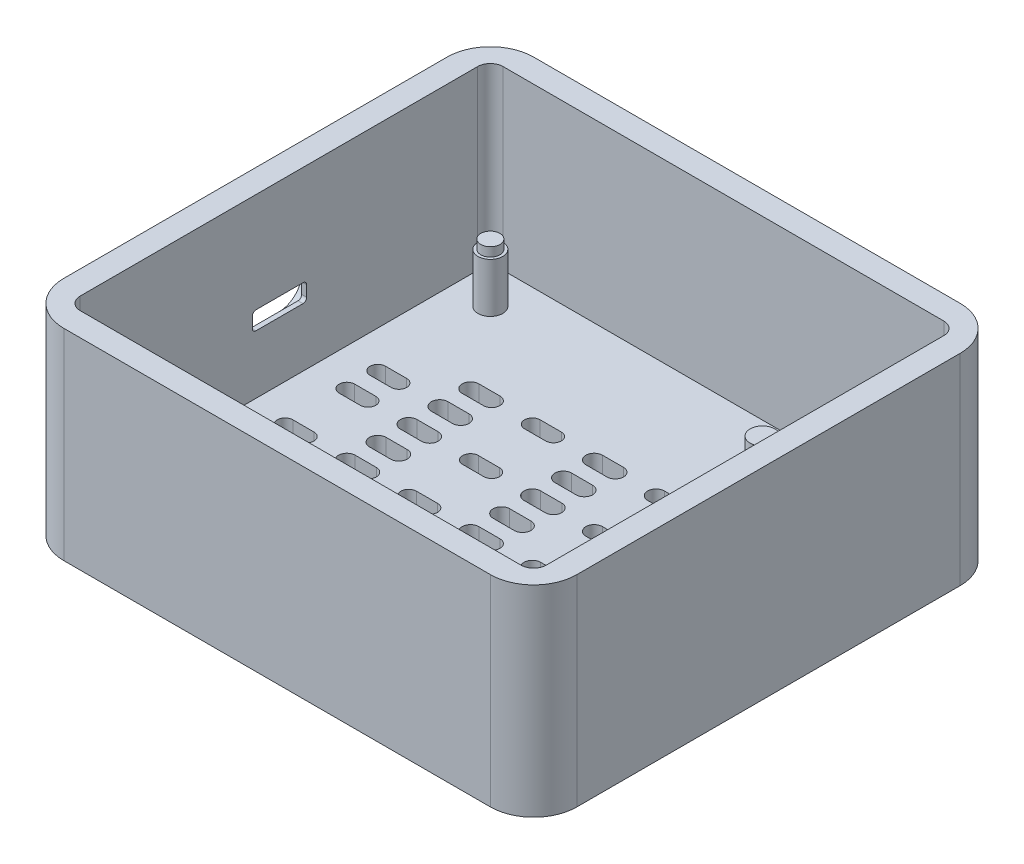
from build123d import *

# Parameters (mm, degrees)
EXTRUDE_1_DEPTH      = 4
CUT_EXTRUDE_1_DEPTH  = 65
SKETCH_7_R           = 2
EXTRUDE_4_DEPTH      = 8
SKETCH_8_R           = 1.55
EXTRUDE_5_DEPTH      = 1.461836357
SKETCH_9_R           = 1.55
EXTRUDE_6_DEPTH      = 1.451210787
SKETCH_10_R          = 2
EXTRUDE_7_DEPTH      = 8
EXTRUDE_8_DEPTH      = 28.55
CUT_EXTRUDE_2_DEPTH  = 9.55
CUT_EXTRUDE_3_DEPTH  = 3
CUT_EXTRUDE_4_DEPTH  = 24.55
SKETCH_16_W          = 7.6
SKETCH_16_H          = 0.085817923
CUT_EXTRUDE_5_DEPTH  = 32
CUT_EXTRUDE_7_DEPTH  = 32
EXTRUDE_9_DEPTH      = 4
EXTRUDE_10_DEPTH     = 4
CUT_EXTRUDE_9_DEPTH  = 2.7
CUT_EXTRUDE_10_DEPTH = 28.55
CUT_EXTRUDE_11_DEPTH = 0.3


with BuildPart() as part:
    # 草图1 → 凸台-拉伸1 (new body)
    with BuildSketch(Plane(origin=(0, 0, 0), x_dir=(1, 0, 0), z_dir=(0, 1, 0))):
        with BuildLine():
            Line((-34.5, 34), (34.5, 34))
            ThreePointArc((34.5, 34), (36.621320344, 33.121320344), (37.5, 31))
            Line((37.5, 31), (37.5, -31))
            ThreePointArc((37.5, -31), (36.621320344, -33.121320344), (34.5, -34))
            Line((34.5, -34), (-34.5, -34))
            ThreePointArc((-34.5, -34), (-36.621320344, -33.121320344), (-37.5, -31))
            Line((-37.5, -31), (-37.5, 31))
            ThreePointArc((-37.5, 31), (-36.621320344, 33.121320344), (-34.5, 34))
        make_face()
    extrude(amount=EXTRUDE_1_DEPTH)

    # 草图2 → 切除-拉伸1 (cut)
    with BuildSketch(Plane(origin=(0, 4, 0), x_dir=(1, 0, 0), z_dir=(0, 1, 0))):
        with BuildLine():
            Line((-1.709039215, 1.342816526), (1.709039215, 1.342816526))
            ThreePointArc((1.709039215, 1.342816526), (3.051855741, 0), (1.709039215, -1.342816526))
            Line((1.709039215, -1.342816526), (-1.709039215, -1.342816526))
            ThreePointArc((-1.709039215, -1.342816526), (-3.051855741, 0), (-1.709039215, 1.342816526))
        make_face()
        with BuildLine():
            Line((18.290960785, 1.342816526), (21.709039215, 1.342816526))
            ThreePointArc((21.709039215, 1.342816526), (23.051855741, 0), (21.709039215, -1.342816526))
            Line((21.709039215, -1.342816526), (18.290960785, -1.342816526))
            ThreePointArc((18.290960785, -1.342816526), (16.948144259, 0), (18.290960785, 1.342816526))
        make_face()
        with BuildLine():
            Line((-21.709039215, 1.342816526), (-18.290960785, 1.342816526))
            ThreePointArc((-18.290960785, 1.342816526), (-16.948144259, 0), (-18.290960785, -1.342816526))
            Line((-18.290960785, -1.342816526), (-21.709039215, -1.342816526))
            ThreePointArc((-21.709039215, -1.342816526), (-23.051855741, 0), (-21.709039215, 1.342816526))
        make_face()
        with BuildLine():
            Line((-1.709039215, -3.657183474), (1.709039215, -3.657183474))
            ThreePointArc((1.709039215, -3.657183474), (3.051855741, -5), (1.709039215, -6.342816526))
            Line((1.709039215, -6.342816526), (-1.709039215, -6.342816526))
            ThreePointArc((-1.709039215, -6.342816526), (-3.051855741, -5), (-1.709039215, -3.657183474))
        make_face()
        with BuildLine():
            Line((8.290960785, -3.657183474), (11.709039215, -3.657183474))
            ThreePointArc((11.709039215, -3.657183474), (13.051855741, -5), (11.709039215, -6.342816526))
            Line((11.709039215, -6.342816526), (8.290960785, -6.342816526))
            ThreePointArc((8.290960785, -6.342816526), (6.948144259, -5), (8.290960785, -3.657183474))
        make_face()
        with BuildLine():
            Line((18.290960785, -3.657183474), (21.709039215, -3.657183474))
            ThreePointArc((21.709039215, -3.657183474), (23.051855741, -5), (21.709039215, -6.342816526))
            Line((21.709039215, -6.342816526), (18.290960785, -6.342816526))
            ThreePointArc((18.290960785, -6.342816526), (16.948144259, -5), (18.290960785, -3.657183474))
        make_face()
        with BuildLine():
            Line((28.290960785, -3.657183474), (31.709039215, -3.657183474))
            ThreePointArc((31.709039215, -3.657183474), (33.051855741, -5), (31.709039215, -6.342816526))
            Line((31.709039215, -6.342816526), (28.290960785, -6.342816526))
            ThreePointArc((28.290960785, -6.342816526), (26.948144259, -5), (28.290960785, -3.657183474))
        make_face()
        with BuildLine():
            Line((-11.709039215, -3.738566294), (-8.290960785, -3.738566294))
            ThreePointArc((-8.290960785, -3.738566294), (-7.029527078, -5), (-8.290960785, -6.261433706))
            Line((-8.290960785, -6.261433706), (-11.709039215, -6.261433706))
            ThreePointArc((-11.709039215, -6.261433706), (-12.970472922, -5), (-11.709039215, -3.738566294))
        make_face()
        with BuildLine():
            Line((-21.709039215, -3.657183474), (-18.290960785, -3.657183474))
            ThreePointArc((-18.290960785, -3.657183474), (-16.948144259, -5), (-18.290960785, -6.342816526))
            Line((-18.290960785, -6.342816526), (-21.709039215, -6.342816526))
            ThreePointArc((-21.709039215, -6.342816526), (-23.051855741, -5), (-21.709039215, -3.657183474))
        make_face()
        with BuildLine():
            Line((-31.709039215, -3.738566294), (-28.290960785, -3.738566294))
            ThreePointArc((-28.290960785, -3.738566294), (-27.029527078, -5), (-28.290960785, -6.261433706))
            Line((-28.290960785, -6.261433706), (-31.709039215, -6.261433706))
            ThreePointArc((-31.709039215, -6.261433706), (-32.970472922, -5), (-31.709039215, -3.738566294))
        make_face()
        with BuildLine():
            Line((-1.709039215, -8.657183474), (1.709039215, -8.657183474))
            ThreePointArc((1.709039215, -8.657183474), (3.051855741, -10), (1.709039215, -11.342816526))
            Line((1.709039215, -11.342816526), (-1.709039215, -11.342816526))
            ThreePointArc((-1.709039215, -11.342816526), (-3.051855741, -10), (-1.709039215, -8.657183474))
        make_face()
        with BuildLine():
            Line((18.290960785, -8.657183474), (21.709039215, -8.657183474))
            ThreePointArc((21.709039215, -8.657183474), (23.051855741, -10), (21.709039215, -11.342816526))
            Line((21.709039215, -11.342816526), (18.290960785, -11.342816526))
            ThreePointArc((18.290960785, -11.342816526), (16.948144259, -10), (18.290960785, -8.657183474))
        make_face()
        with BuildLine():
            Line((28.290960785, -8.657183474), (31.709039215, -8.657183474))
            ThreePointArc((31.709039215, -8.657183474), (33.051855741, -10), (31.709039215, -11.342816526))
            Line((31.709039215, -11.342816526), (28.290960785, -11.342816526))
            ThreePointArc((28.290960785, -11.342816526), (26.948144259, -10), (28.290960785, -8.657183474))
        make_face()
        with BuildLine():
            Line((-21.709039215, -8.657183474), (-18.290960785, -8.657183474))
            ThreePointArc((-18.290960785, -8.657183474), (-16.948144259, -10), (-18.290960785, -11.342816526))
            Line((-18.290960785, -11.342816526), (-21.709039215, -11.342816526))
            ThreePointArc((-21.709039215, -11.342816526), (-23.051855741, -10), (-21.709039215, -8.657183474))
        make_face()
        with BuildLine():
            Line((-31.709039215, -8.738566294), (-28.290960785, -8.738566294))
            ThreePointArc((-28.290960785, -8.738566294), (-27.029527078, -10), (-28.290960785, -11.261433706))
            Line((-28.290960785, -11.261433706), (-31.709039215, -11.261433706))
            ThreePointArc((-31.709039215, -11.261433706), (-32.970472922, -10), (-31.709039215, -8.738566294))
        make_face()
        with BuildLine():
            Line((-1.709039215, -13.657183474), (1.709039215, -13.657183474))
            ThreePointArc((1.709039215, -13.657183474), (3.051855741, -15), (1.709039215, -16.342816526))
            Line((1.709039215, -16.342816526), (-1.709039215, -16.342816526))
            ThreePointArc((-1.709039215, -16.342816526), (-3.051855741, -15), (-1.709039215, -13.657183474))
        make_face()
        with BuildLine():
            Line((8.290960785, -13.657183474), (11.709039215, -13.657183474))
            ThreePointArc((11.709039215, -13.657183474), (13.051855741, -15), (11.709039215, -16.342816526))
            Line((11.709039215, -16.342816526), (8.290960785, -16.342816526))
            ThreePointArc((8.290960785, -16.342816526), (6.948144259, -15), (8.290960785, -13.657183474))
        make_face()
        with BuildLine():
            Line((18.290960785, -13.657183474), (21.709039215, -13.657183474))
            ThreePointArc((21.709039215, -13.657183474), (23.051855741, -15), (21.709039215, -16.342816526))
            Line((21.709039215, -16.342816526), (18.290960785, -16.342816526))
            ThreePointArc((18.290960785, -16.342816526), (16.948144259, -15), (18.290960785, -13.657183474))
        make_face()
        with BuildLine():
            Line((-11.709039215, -13.738566294), (-8.290960785, -13.738566294))
            ThreePointArc((-8.290960785, -13.738566294), (-7.029527078, -15), (-8.290960785, -16.261433706))
            Line((-8.290960785, -16.261433706), (-11.709039215, -16.261433706))
            ThreePointArc((-11.709039215, -16.261433706), (-12.970472922, -15), (-11.709039215, -13.738566294))
        make_face()
        with BuildLine():
            Line((-21.709039215, -13.657183474), (-18.290960785, -13.657183474))
            ThreePointArc((-18.290960785, -13.657183474), (-16.948144259, -15), (-18.290960785, -16.342816526))
            Line((-18.290960785, -16.342816526), (-21.709039215, -16.342816526))
            ThreePointArc((-21.709039215, -16.342816526), (-23.051855741, -15), (-21.709039215, -13.657183474))
        make_face()
        with BuildLine():
            Line((-1.709039215, 6.342816526), (1.709039215, 6.342816526))
            ThreePointArc((1.709039215, 6.342816526), (3.051855741, 5), (1.709039215, 3.657183474))
            Line((1.709039215, 3.657183474), (-1.709039215, 3.657183474))
            ThreePointArc((-1.709039215, 3.657183474), (-3.051855741, 5), (-1.709039215, 6.342816526))
        make_face()
        with BuildLine():
            Line((8.290960785, 6.342816526), (11.709039215, 6.342816526))
            ThreePointArc((11.709039215, 6.342816526), (13.051855741, 5), (11.709039215, 3.657183474))
            Line((11.709039215, 3.657183474), (8.290960785, 3.657183474))
            ThreePointArc((8.290960785, 3.657183474), (6.948144259, 5), (8.290960785, 6.342816526))
        make_face()
        with BuildLine():
            Line((18.290960785, 6.342816526), (21.709039215, 6.342816526))
            ThreePointArc((21.709039215, 6.342816526), (23.051855741, 5), (21.709039215, 3.657183474))
            Line((21.709039215, 3.657183474), (18.290960785, 3.657183474))
            ThreePointArc((18.290960785, 3.657183474), (16.948144259, 5), (18.290960785, 6.342816526))
        make_face()
        with BuildLine():
            Line((28.290960785, 6.342816526), (31.709039215, 6.342816526))
            ThreePointArc((31.709039215, 6.342816526), (33.051855741, 5), (31.709039215, 3.657183474))
            Line((31.709039215, 3.657183474), (28.290960785, 3.657183474))
            ThreePointArc((28.290960785, 3.657183474), (26.948144259, 5), (28.290960785, 6.342816526))
        make_face()
        with BuildLine():
            Line((-11.709039215, 6.261433706), (-8.290960785, 6.261433706))
            ThreePointArc((-8.290960785, 6.261433706), (-7.029527078, 5), (-8.290960785, 3.738566294))
            Line((-8.290960785, 3.738566294), (-11.709039215, 3.738566294))
            ThreePointArc((-11.709039215, 3.738566294), (-12.970472922, 5), (-11.709039215, 6.261433706))
        make_face()
        with BuildLine():
            Line((-21.709039215, 6.342816526), (-18.290960785, 6.342816526))
            ThreePointArc((-18.290960785, 6.342816526), (-16.948144259, 5), (-18.290960785, 3.657183474))
            Line((-18.290960785, 3.657183474), (-21.709039215, 3.657183474))
            ThreePointArc((-21.709039215, 3.657183474), (-23.051855741, 5), (-21.709039215, 6.342816526))
        make_face()
        with BuildLine():
            Line((-31.709039215, 6.261433706), (-28.290960785, 6.261433706))
            ThreePointArc((-28.290960785, 6.261433706), (-27.029527078, 5), (-28.290960785, 3.738566294))
            Line((-28.290960785, 3.738566294), (-31.709039215, 3.738566294))
            ThreePointArc((-31.709039215, 3.738566294), (-32.970472922, 5), (-31.709039215, 6.261433706))
        make_face()
        with BuildLine():
            Line((-1.709039215, 11.342816526), (1.709039215, 11.342816526))
            ThreePointArc((1.709039215, 11.342816526), (3.051855741, 10), (1.709039215, 8.657183474))
            Line((1.709039215, 8.657183474), (-1.709039215, 8.657183474))
            ThreePointArc((-1.709039215, 8.657183474), (-3.051855741, 10), (-1.709039215, 11.342816526))
        make_face()
        with BuildLine():
            Line((18.290960785, 11.342816526), (21.709039215, 11.342816526))
            ThreePointArc((21.709039215, 11.342816526), (23.051855741, 10), (21.709039215, 8.657183474))
            Line((21.709039215, 8.657183474), (18.290960785, 8.657183474))
            ThreePointArc((18.290960785, 8.657183474), (16.948144259, 10), (18.290960785, 11.342816526))
        make_face()
        with BuildLine():
            Line((28.290960785, 11.342816526), (31.709039215, 11.342816526))
            ThreePointArc((31.709039215, 11.342816526), (33.051855741, 10), (31.709039215, 8.657183474))
            Line((31.709039215, 8.657183474), (28.290960785, 8.657183474))
            ThreePointArc((28.290960785, 8.657183474), (26.948144259, 10), (28.290960785, 11.342816526))
        make_face()
        with BuildLine():
            Line((-21.709039215, 11.342816526), (-18.290960785, 11.342816526))
            ThreePointArc((-18.290960785, 11.342816526), (-16.948144259, 10), (-18.290960785, 8.657183474))
            Line((-18.290960785, 8.657183474), (-21.709039215, 8.657183474))
            ThreePointArc((-21.709039215, 8.657183474), (-23.051855741, 10), (-21.709039215, 11.342816526))
        make_face()
        with BuildLine():
            Line((-31.709039215, 11.261433706), (-28.290960785, 11.261433706))
            ThreePointArc((-28.290960785, 11.261433706), (-27.029527078, 10), (-28.290960785, 8.738566294))
            Line((-28.290960785, 8.738566294), (-31.709039215, 8.738566294))
            ThreePointArc((-31.709039215, 8.738566294), (-32.970472922, 10), (-31.709039215, 11.261433706))
        make_face()
        with BuildLine():
            Line((-1.709039215, 16.342816526), (1.709039215, 16.342816526))
            ThreePointArc((1.709039215, 16.342816526), (3.051855741, 15), (1.709039215, 13.657183474))
            Line((1.709039215, 13.657183474), (-1.709039215, 13.657183474))
            ThreePointArc((-1.709039215, 13.657183474), (-3.051855741, 15), (-1.709039215, 16.342816526))
        make_face()
        with BuildLine():
            Line((8.290960785, 16.342816526), (11.709039215, 16.342816526))
            ThreePointArc((11.709039215, 16.342816526), (13.051855741, 15), (11.709039215, 13.657183474))
            Line((11.709039215, 13.657183474), (8.290960785, 13.657183474))
            ThreePointArc((8.290960785, 13.657183474), (6.948144259, 15), (8.290960785, 16.342816526))
        make_face()
        with BuildLine():
            Line((18.290960785, 16.342816526), (21.709039215, 16.342816526))
            ThreePointArc((21.709039215, 16.342816526), (23.051855741, 15), (21.709039215, 13.657183474))
            Line((21.709039215, 13.657183474), (18.290960785, 13.657183474))
            ThreePointArc((18.290960785, 13.657183474), (16.948144259, 15), (18.290960785, 16.342816526))
        make_face()
        with BuildLine():
            Line((-11.709039215, 16.261433706), (-8.290960785, 16.261433706))
            ThreePointArc((-8.290960785, 16.261433706), (-7.029527078, 15), (-8.290960785, 13.738566294))
            Line((-8.290960785, 13.738566294), (-11.709039215, 13.738566294))
            ThreePointArc((-11.709039215, 13.738566294), (-12.970472922, 15), (-11.709039215, 16.261433706))
        make_face()
        with BuildLine():
            Line((-21.709039215, 16.342816526), (-18.290960785, 16.342816526))
            ThreePointArc((-18.290960785, 16.342816526), (-16.948144259, 15), (-18.290960785, 13.657183474))
            Line((-18.290960785, 13.657183474), (-21.709039215, 13.657183474))
            ThreePointArc((-21.709039215, 13.657183474), (-23.051855741, 15), (-21.709039215, 16.342816526))
        make_face()
    extrude(amount=-CUT_EXTRUDE_1_DEPTH, mode=Mode.SUBTRACT)

    # 草图7 → 凸台-拉伸4 (add)
    with BuildSketch(Plane(origin=(0, 4, 0), x_dir=(1, 0, 0), z_dir=(0, 1, 0))):
        with Locations((-31.621320344, 28.121320344)):
            Circle(SKETCH_7_R)
        with Locations((-31.621320344, -28.121320344)):
            Circle(SKETCH_7_R)
    extrude(amount=EXTRUDE_4_DEPTH)

    # 草图8 → 凸台-拉伸5 (add)
    with BuildSketch(Plane(origin=(0, 12, 0), x_dir=(1, 0, 0), z_dir=(0, 1, 0))):
        with Locations((-31.621320344, -28.121320344)):
            Circle(SKETCH_8_R)
    extrude(amount=EXTRUDE_5_DEPTH)

    # 草图9 → 凸台-拉伸6 (add)
    with BuildSketch(Plane(origin=(0, 12, 0), x_dir=(1, 0, 0), z_dir=(0, 1, 0))):
        with Locations((-31.621320344, 28.121320344)):
            Circle(SKETCH_9_R)
    extrude(amount=EXTRUDE_6_DEPTH)

    # 草图10 → 凸台-拉伸7 (add)
    with BuildSketch(Plane(origin=(0, 4, 0), x_dir=(1, 0, 0), z_dir=(0, 1, 0))):
        with Locations((16.546, -27.048136821)):
            Circle(SKETCH_10_R)
        with Locations((16.546, 23.975895567)):
            Circle(SKETCH_10_R)
    extrude(amount=EXTRUDE_7_DEPTH)

    # 草图11 → 凸台-拉伸8 (add)
    with BuildSketch(Plane.XZ):
        with BuildLine():
            Line((-34.5, -38), (34.5, -38))
            ThreePointArc((34.5, -38), (39.449747468, -35.949747468), (41.5, -31))
            Line((41.5, -31), (41.5, 31))
            ThreePointArc((41.5, 31), (39.449747468, 35.949747468), (34.5, 38))
            Line((34.5, 38), (-34.5, 38))
            ThreePointArc((-34.5, 38), (-39.449747468, 35.949747468), (-41.5, 31))
            Line((-41.5, 31), (-41.5, -31))
            ThreePointArc((-41.5, -31), (-39.449747468, -35.949747468), (-34.5, -38))
        make_face()
        with BuildLine():
            Line((-34.5, -34), (34.5, -34))
            ThreePointArc((34.5, -34), (36.621320344, -33.121320344), (37.5, -31))
            Line((37.5, -31), (37.5, 31))
            ThreePointArc((37.5, 31), (36.621320344, 33.121320344), (34.5, 34))
            Line((34.5, 34), (-34.5, 34))
            ThreePointArc((-34.5, 34), (-36.621320344, 33.121320344), (-37.5, 31))
            Line((-37.5, 31), (-37.5, -31))
            ThreePointArc((-37.5, -31), (-36.621320344, -33.121320344), (-34.5, -34))
        make_face(mode=Mode.SUBTRACT)
    extrude(amount=-EXTRUDE_8_DEPTH)

    # 草图12 → 切除-拉伸2 (cut)
    with BuildSketch(Plane.ZY.offset(41.5)):
        with BuildLine():
            Line((-3.8715, 9.55), (3.7285, 9.55))
            ThreePointArc((3.7285, 9.55), (4.152764069, 9.725735931), (4.3285, 10.15))
            Line((4.3285, 10.15), (4.3285, 11.8))
            ThreePointArc((4.3285, 11.8), (4.152764069, 12.224264069), (3.7285, 12.4))
            Line((3.7285, 12.4), (-3.8715, 12.4))
            ThreePointArc((-3.8715, 12.4), (-4.295764069, 12.224264069), (-4.4715, 11.8))
            Line((-4.4715, 11.8), (-4.4715, 10.15))
            ThreePointArc((-4.4715, 10.15), (-4.295764069, 9.725735931), (-3.8715, 9.55))
        make_face()
    extrude(amount=-CUT_EXTRUDE_2_DEPTH, mode=Mode.SUBTRACT)

    # 草图13 → 切除-拉伸3 (cut)
    with BuildSketch(Plane.ZY.offset(41.5)):
        with BuildLine():
            Line((3.7285, 14.4), (-3.8715, 14.4))
            ThreePointArc((-3.8715, 14.4), (-5.709977631, 13.638477631), (-6.4715, 11.8))
            Line((-6.4715, 11.8), (-6.4715, 10.15))
            ThreePointArc((-6.4715, 10.15), (-5.709977631, 8.311522369), (-3.8715, 7.55))
            Line((-3.8715, 7.55), (3.7285, 7.55))
            ThreePointArc((3.7285, 7.55), (5.566977631, 8.311522369), (6.3285, 10.15))
            Line((6.3285, 10.15), (6.3285, 11.8))
            ThreePointArc((6.3285, 11.8), (5.566977631, 13.638477631), (3.7285, 14.4))
        make_face()
    extrude(amount=-CUT_EXTRUDE_3_DEPTH, mode=Mode.SUBTRACT)

    # 草图15 → 切除-拉伸4 (cut)
    with BuildSketch(Plane(origin=(0, 28.55, 0), x_dir=(1, 0, 0), z_dir=(0, 1, 0))):
        with BuildLine():
            ThreePointArc((-35.65, -34), (-36.958147545, -33.458147545), (-37.5, -32.15))
            Line((-37.5, -32.15), (-37.5, -31))
            ThreePointArc((-37.5, -31), (-36.621320344, -33.121320344), (-34.5, -34))
            Line((-34.5, -34), (-35.65, -34))
        make_face()
        with BuildLine():
            Line((34.5, -34), (35.65, -34))
            ThreePointArc((35.65, -34), (36.958147545, -33.458147545), (37.5, -32.15))
            Line((37.5, -32.15), (37.5, -31))
            ThreePointArc((37.5, -31), (36.621320344, -33.121320344), (34.5, -34))
        make_face()
        with BuildLine():
            Line((-37.5, 32.15), (-37.5, 31))
            ThreePointArc((-37.5, 31), (-36.621320344, 33.121320344), (-34.5, 34))
            Line((-34.5, 34), (-35.65, 34))
            ThreePointArc((-35.65, 34), (-36.958147545, 33.458147545), (-37.5, 32.15))
        make_face()
        with BuildLine():
            ThreePointArc((35.65, 34), (36.958147545, 33.458147545), (37.5, 32.15))
            Line((37.5, 32.15), (37.5, 31))
            ThreePointArc((37.5, 31), (36.621320344, 33.121320344), (34.5, 34))
            Line((34.5, 34), (35.65, 34))
        make_face()
    extrude(amount=-CUT_EXTRUDE_4_DEPTH, mode=Mode.SUBTRACT)

    # 草图16 → 切除-拉伸5 (cut)
    with BuildSketch(Plane.ZY.offset(38.5)):
        with Locations((-0.0715, 9.507091039)):
            Rectangle(SKETCH_16_W, SKETCH_16_H)
        with BuildLine():
            ThreePointArc((-3.8715, 9.464182077), (-4.295764069, 9.639918008), (-4.4715, 10.064182077))
            Line((-4.4715, 10.064182077), (-4.4715, 10.15))
            ThreePointArc((-4.4715, 10.15), (-4.295764069, 9.725735931), (-3.8715, 9.55))
            Line((-3.8715, 9.55), (-3.8715, 9.464182077))
        make_face()
        with BuildLine():
            Line((3.7285, 9.55), (3.7285, 9.464182077))
            ThreePointArc((3.7285, 9.464182077), (4.152764069, 9.639918008), (4.3285, 10.064182077))
            Line((4.3285, 10.064182077), (4.3285, 10.15))
            ThreePointArc((4.3285, 10.15), (4.152764069, 9.725735931), (3.7285, 9.55))
        make_face()
    extrude(amount=-CUT_EXTRUDE_5_DEPTH, mode=Mode.SUBTRACT)

    # 草图19 → 切除-拉伸7 (cut)
    with BuildSketch(Plane.ZY.offset(41.5)):
        with BuildLine():
            Line((-4.483592089, 15.8), (-4.483592089, 14.064182077))
            ThreePointArc((-4.483592089, 14.064182077), (-4.307856158, 13.639918008), (-3.883592089, 13.464182077))
            Line((-3.883592089, 13.464182077), (3.716407911, 13.464182077))
            ThreePointArc((3.716407911, 13.464182077), (4.14067198, 13.639918008), (4.316407911, 14.064182077))
            Line((4.316407911, 14.064182077), (4.316407911, 15.8))
            ThreePointArc((4.316407911, 15.8), (4.14067198, 16.224264069), (3.716407911, 16.4))
            Line((3.716407911, 16.4), (-3.883592089, 16.4))
            ThreePointArc((-3.883592089, 16.4), (-4.307856158, 16.224264069), (-4.483592089, 15.8))
        make_face()
    extrude(amount=-CUT_EXTRUDE_7_DEPTH, mode=Mode.SUBTRACT)

    # 草图21 → 凸台-拉伸9 (add)
    with BuildSketch(Plane(origin=(0, 28.55, 0), x_dir=(1, 0, 0), z_dir=(0, 1, 0))):
        with BuildLine():
            Line((-41.5, 31), (-41.5, -31))
            ThreePointArc((-41.5, -31), (-39.449747468, -35.949747468), (-34.5, -38))
            Line((-34.5, -38), (34.5, -38))
            ThreePointArc((34.5, -38), (39.449747468, -35.949747468), (41.5, -31))
            Line((41.5, -31), (41.5, 31))
            ThreePointArc((41.5, 31), (39.449747468, 35.949747468), (34.5, 38))
            Line((34.5, 38), (-34.5, 38))
            ThreePointArc((-34.5, 38), (-39.449747468, 35.949747468), (-41.5, 31))
        make_face()
        with BuildLine():
            Line((-35.65, -34), (35.65, -34))
            ThreePointArc((35.65, -34), (36.958147545, -33.458147545), (37.5, -32.15))
            Line((37.5, -32.15), (37.5, 32.15))
            ThreePointArc((37.5, 32.15), (36.958147545, 33.458147545), (35.65, 34))
            Line((35.65, 34), (-35.65, 34))
            ThreePointArc((-35.65, 34), (-36.958147545, 33.458147545), (-37.5, 32.15))
            Line((-37.5, 32.15), (-37.5, -32.15))
            ThreePointArc((-37.5, -32.15), (-36.958147545, -33.458147545), (-35.65, -34))
        make_face(mode=Mode.SUBTRACT)
    extrude(amount=EXTRUDE_9_DEPTH)

    # 草图22 → 凸台-拉伸10 (add)
    with BuildSketch(Plane.ZY.offset(41.5)):
        with BuildLine():
            Line((4.316407911, 14.332659529), (4.316407911, 14.064182077))
            ThreePointArc((4.316407911, 14.064182077), (4.14067198, 13.639918008), (3.716407911, 13.464182077))
            Line((3.716407911, 13.464182077), (-3.883592089, 13.464182077))
            ThreePointArc((-3.883592089, 13.464182077), (-4.307856158, 13.639918008), (-4.483592089, 14.064182077))
            Line((-4.483592089, 14.064182077), (-4.483592089, 14.326923678))
            ThreePointArc((-4.483592089, 14.326923678), (-5.914957784, 13.407569683), (-6.4715, 11.8))
            Line((-6.4715, 11.8), (-6.4715, 10.15))
            ThreePointArc((-6.4715, 10.15), (-5.709977631, 8.311522369), (-3.8715, 7.55))
            Line((-3.8715, 7.55), (3.7285, 7.55))
            ThreePointArc((3.7285, 7.55), (5.566977631, 8.311522369), (6.3285, 10.15))
            Line((6.3285, 10.15), (6.3285, 11.8))
            ThreePointArc((6.3285, 11.8), (5.764250546, 13.417318681), (4.316407911, 14.332659529))
        make_face()
    extrude(amount=-EXTRUDE_10_DEPTH)

    # 草图23 → 切除-拉伸9 (cut)
    with BuildSketch(Plane.ZY.offset(41.5)):
        with BuildLine():
            Line((7.316407911, 15.8), (7.316407911, 14.064182077))
            ThreePointArc((7.316407911, 14.064182077), (6.261992323, 11.518597665), (3.716407911, 10.464182077))
            Line((3.716407911, 10.464182077), (-3.883592089, 10.464182077))
            ThreePointArc((-3.883592089, 10.464182077), (-6.429176501, 11.518597665), (-7.483592089, 14.064182077))
            Line((-7.483592089, 14.064182077), (-7.483592089, 15.8))
            ThreePointArc((-7.483592089, 15.8), (-6.429176501, 18.345584412), (-3.883592089, 19.4))
            Line((-3.883592089, 19.4), (3.716407911, 19.4))
            ThreePointArc((3.716407911, 19.4), (6.261992323, 18.345584412), (7.316407911, 15.8))
        make_face()
        with BuildLine():
            Line((4.316407911, 15.8), (4.316407911, 14.064182077))
            ThreePointArc((4.316407911, 14.064182077), (4.14067198, 13.639918008), (3.716407911, 13.464182077))
            Line((3.716407911, 13.464182077), (-3.883592089, 13.464182077))
            ThreePointArc((-3.883592089, 13.464182077), (-4.307856158, 13.639918008), (-4.483592089, 14.064182077))
            Line((-4.483592089, 14.064182077), (-4.483592089, 15.8))
            ThreePointArc((-4.483592089, 15.8), (-4.307856158, 16.224264069), (-3.883592089, 16.4))
            Line((-3.883592089, 16.4), (3.716407911, 16.4))
            ThreePointArc((3.716407911, 16.4), (4.14067198, 16.224264069), (4.316407911, 15.8))
        make_face(mode=Mode.SUBTRACT)
    extrude(amount=-CUT_EXTRUDE_9_DEPTH, mode=Mode.SUBTRACT)

    # 草图25 → 切除-拉伸10 (cut)
    with BuildSketch(Plane(origin=(0, 32.55, 0), x_dir=(1, 0, 0), z_dir=(0, 1, 0))):
        with BuildLine():
            Line((-37.7, 32.15), (-37.7, -32.15))
            ThreePointArc((-37.7, -32.15), (-37.099568901, -33.599568901), (-35.65, -34.2))
            Line((-35.65, -34.2), (35.65, -34.2))
            ThreePointArc((35.65, -34.2), (37.099568901, -33.599568901), (37.7, -32.15))
            Line((37.7, -32.15), (37.7, 32.15))
            ThreePointArc((37.7, 32.15), (37.099568901, 33.599568901), (35.65, 34.2))
            Line((35.65, 34.2), (-35.65, 34.2))
            ThreePointArc((-35.65, 34.2), (-37.099568901, 33.599568901), (-37.7, 32.15))
        make_face()
        with BuildLine():
            ThreePointArc((-35.65, -34), (-36.958147545, -33.458147545), (-37.5, -32.15))
            Line((-37.5, -32.15), (-37.5, 32.15))
            ThreePointArc((-37.5, 32.15), (-36.958147545, 33.458147545), (-35.65, 34))
            Line((-35.65, 34), (35.65, 34))
            ThreePointArc((35.65, 34), (36.958147545, 33.458147545), (37.5, 32.15))
            Line((37.5, 32.15), (37.5, -32.15))
            ThreePointArc((37.5, -32.15), (36.958147545, -33.458147545), (35.65, -34))
            Line((35.65, -34), (-35.65, -34))
        make_face(mode=Mode.SUBTRACT)
    extrude(amount=-CUT_EXTRUDE_10_DEPTH, mode=Mode.SUBTRACT)

    # 草图26 → 切除-拉伸11 (cut)
    with BuildSketch(Plane.ZY.offset(38.8)):
        with BuildLine():
            Line((3.716407911, 19.4), (-3.883592089, 19.4))
            ThreePointArc((-3.883592089, 19.4), (-6.429176501, 18.345584412), (-7.483592089, 15.8))
            Line((-7.483592089, 15.8), (-7.483592089, 14.064182077))
            ThreePointArc((-7.483592089, 14.064182077), (-6.429176501, 11.518597665), (-3.883592089, 10.464182077))
            Line((-3.883592089, 10.464182077), (3.716407911, 10.464182077))
            ThreePointArc((3.716407911, 10.464182077), (6.261992323, 11.518597665), (7.316407911, 14.064182077))
            Line((7.316407911, 14.064182077), (7.316407911, 15.8))
            ThreePointArc((7.316407911, 15.8), (6.261992323, 18.345584412), (3.716407911, 19.4))
        make_face()
    extrude(amount=-CUT_EXTRUDE_11_DEPTH, mode=Mode.SUBTRACT)


solid = part.part
